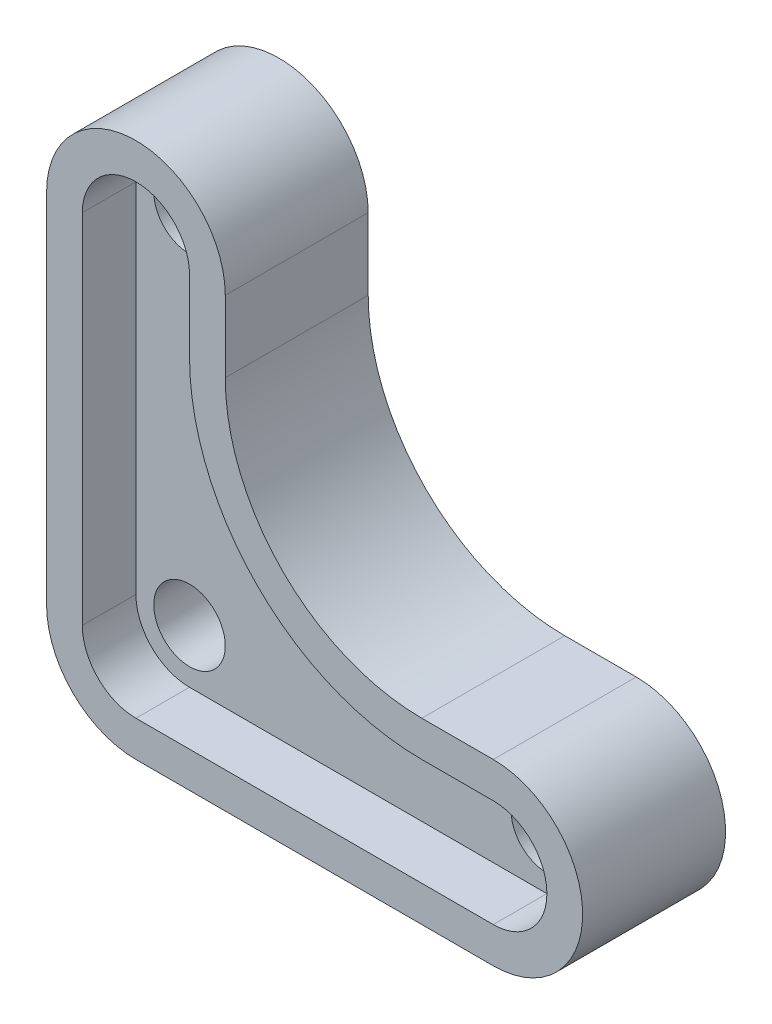
from build123d import *

# Parameters (mm, degrees)
BOSS_EXTRUDE1_DEPTH          = 8
CUT_EXTRUDE1_DEPTH           = 3
F_4_0_4_DIAMETER_HOLE1_D     = 4
F_4_0_4_DIAMETER_HOLE1_DEPTH = 8
FILLET1_R                    = 3
FILLET2_R                    = 5
FILLET3_R                    = 11
FILLET4_R                    = 13


with BuildPart() as part:
    # Sketch1 → Boss-Extrude1 (new body)
    with BuildSketch(Plane.XY.offset(13)):
        with BuildLine():
            Line((-15, 5), (-15, 20))
            ThreePointArc((-15, 20), (-20, 25), (-25, 20))
            Line((-25, 20), (-25, -5))
            Line((-25, -5), (0, -5))
            ThreePointArc((0, -5), (5, 0), (0, 5))
            Line((0, 5), (-15, 5))
        make_face()
    extrude(amount=-BOSS_EXTRUDE1_DEPTH)

    # Sketch2 → Cut-Extrude1 (cut)
    with BuildSketch(Plane.XY.offset(13)):
        with BuildLine():
            Line((-23, 20), (-23, -3))
            Line((-23, -3), (0, -3))
            ThreePointArc((0, -3), (3, 0), (0, 3))
            Line((0, 3), (-17, 3))
            Line((-17, 3), (-17, 20))
            ThreePointArc((-17, 20), (-20, 23), (-23, 20))
        make_face()
    extrude(amount=-CUT_EXTRUDE1_DEPTH, mode=Mode.SUBTRACT)

    # Ø4.0 (4) Diameter Hole1
    with Locations(Plane(origin=(0, 0, 5), x_dir=(-1, 0, 0), z_dir=(0, 0, -1))):
        with Locations((20, 20), (20, 0), (0, 0)):
            Hole(F_4_0_4_DIAMETER_HOLE1_D / 2, depth=F_4_0_4_DIAMETER_HOLE1_DEPTH)

    # Fillet1
    fillet1_edges = [part.edges().sort_by_distance(p)[0] for p in [
        (-23, -3, 11.5),
    ]]
    fillet(fillet1_edges, radius=FILLET1_R)

    # Fillet2
    fillet2_edges = [part.edges().sort_by_distance(p)[0] for p in [
        (-25, -5, 9),
    ]]
    fillet(fillet2_edges, radius=FILLET2_R)

    # Fillet3
    fillet3_edges = [part.edges().sort_by_distance(p)[0] for p in [
        (-15, 5, 9),
    ]]
    fillet(fillet3_edges, radius=FILLET3_R)

    # Fillet4
    fillet4_edges = [part.edges().sort_by_distance(p)[0] for p in [
        (-17, 3, 11.5),
    ]]
    fillet(fillet4_edges, radius=FILLET4_R)


solid = part.part
